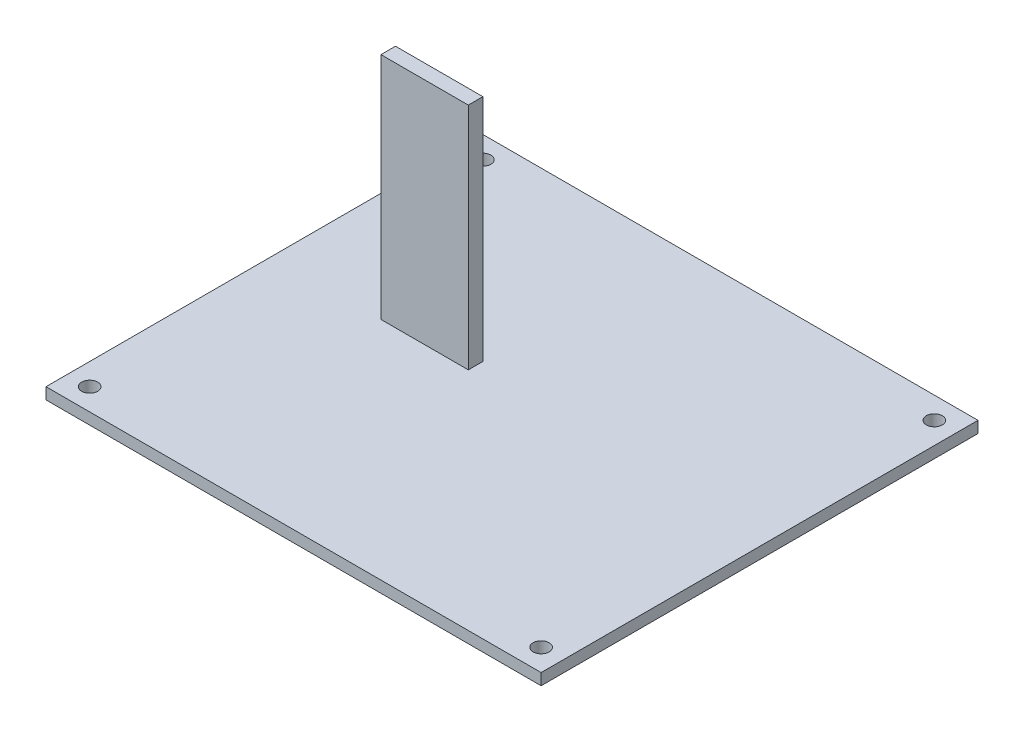
from build123d import *

# Parameters (mm, degrees)
SKETCH1_W           = 86.36
SKETCH1_H           = 76.2
SKETCH1_R           = 1.397
BOSS_EXTRUDE1_DEPTH = 2
SKETCH2_W           = 15.24
SKETCH2_H           = 2.54
BOSS_EXTRUDE2_DEPTH = 40


with BuildPart() as part:
    # Sketch1 → Boss-Extrude1 (new body)
    with BuildSketch(Plane(origin=(0, 0, 0), x_dir=(1, 0, 0), z_dir=(0, 1, 0))):
        Rectangle(SKETCH1_W, SKETCH1_H)
        with Locations((-39.37, 34.29)):
            Circle(SKETCH1_R, mode=Mode.SUBTRACT)
        with Locations((39.37, -34.29)):
            Circle(SKETCH1_R, mode=Mode.SUBTRACT)
        with Locations((-39.37, -34.29)):
            Circle(SKETCH1_R, mode=Mode.SUBTRACT)
        with Locations((39.37, 34.29)):
            Circle(SKETCH1_R, mode=Mode.SUBTRACT)
    extrude(amount=BOSS_EXTRUDE1_DEPTH)

    # Sketch2 → Boss-Extrude2 (add)
    with BuildSketch(Plane(origin=(0, 2, 0), x_dir=(1, 0, 0), z_dir=(0, 1, 0))):
        with Locations((-16.51, 2.54)):
            Rectangle(SKETCH2_W, SKETCH2_H)
    extrude(amount=BOSS_EXTRUDE2_DEPTH)


solid = part.part
